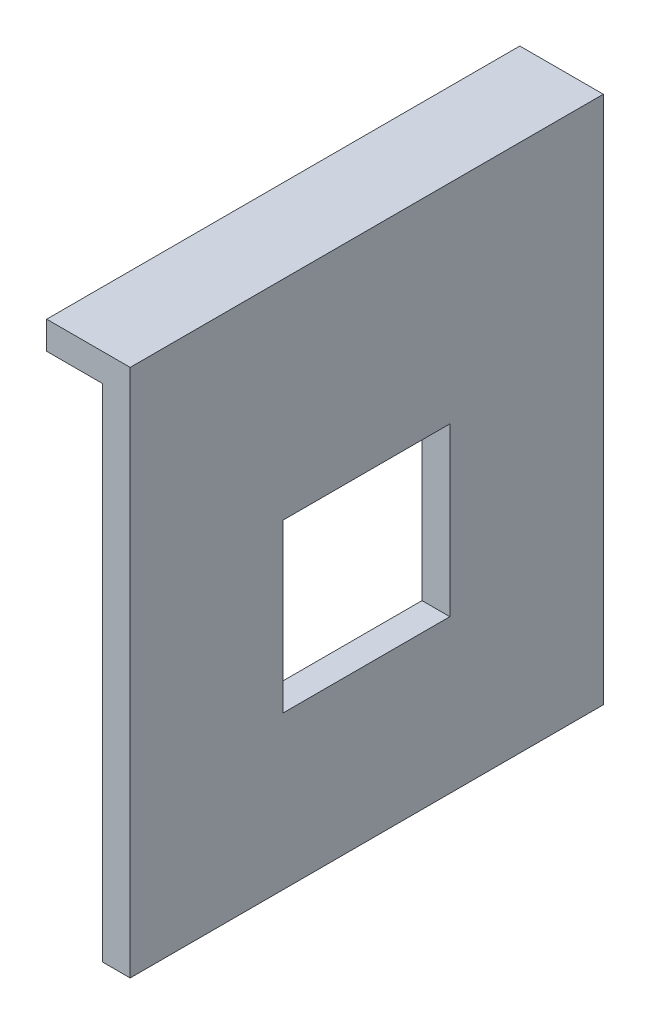
from build123d import *

# Parameters (mm, degrees)
SKETCH1_W           = 5
SKETCH1_H           = 85
BOSS_EXTRUDE1_DEPTH = 95
SKETCH2_W           = 85
SKETCH2_H           = 5
BOSS_EXTRUDE2_DEPTH = 10
SKETCH3_W           = 30
SKETCH3_H           = 30
CUT_EXTRUDE1_DEPTH  = 10


with BuildPart() as part:
    # Sketch1 → Boss-Extrude1 (new body)
    with BuildSketch(Plane(origin=(0, 0, 0), x_dir=(1, 0, 0), z_dir=(0, 1, 0))):
        with Locations((-2.5, -42.5)):
            Rectangle(SKETCH1_W, SKETCH1_H)
    extrude(amount=BOSS_EXTRUDE1_DEPTH)

    # Sketch2 → Boss-Extrude2 (add)
    with BuildSketch(Plane.ZY.offset(5)):
        with Locations((42.5, 92.5)):
            Rectangle(SKETCH2_W, SKETCH2_H)
    extrude(amount=BOSS_EXTRUDE2_DEPTH)

    # Sketch3 → Cut-Extrude1 (cut)
    with BuildSketch(Plane.ZY.offset(5)):
        with Locations((42.573593129, 42.5)):
            Rectangle(SKETCH3_W, SKETCH3_H)
    extrude(amount=-CUT_EXTRUDE1_DEPTH, mode=Mode.SUBTRACT)


solid = part.part
